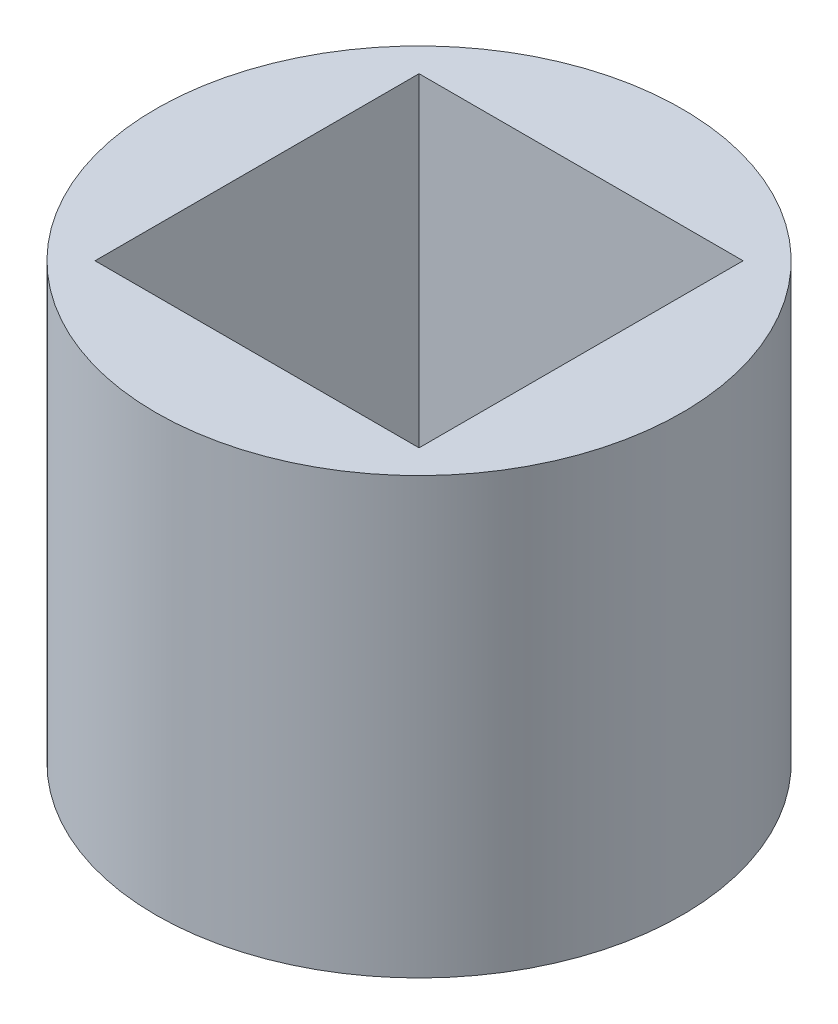
from build123d import *

# Parameters (mm, degrees)
SKETCH1_R           = 12.7
SKETCH1_W           = 15.64
SKETCH1_H           = 15.64
BOSS_EXTRUDE1_DEPTH = 21


with BuildPart() as part:
    # Sketch1 → Boss-Extrude1 (new body)
    with BuildSketch(Plane(origin=(0, 0, 0), x_dir=(1, 0, 0), z_dir=(0, 1, 0))):
        Circle(SKETCH1_R)
        Rectangle(SKETCH1_W, SKETCH1_H, mode=Mode.SUBTRACT)
    extrude(amount=BOSS_EXTRUDE1_DEPTH)


solid = part.part
